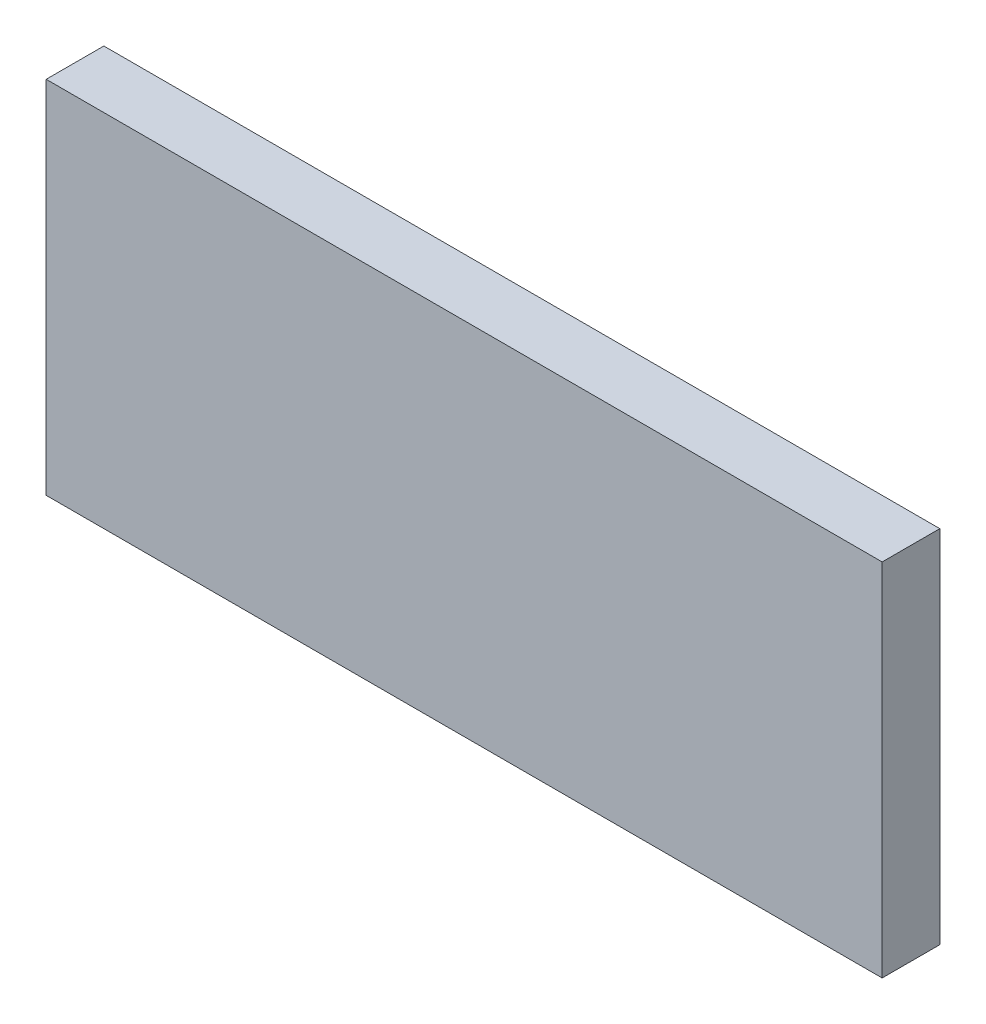
from build123d import *

# Parameters (mm, degrees)
SKETCH1_W           = 58
SKETCH1_H           = 25
BOSS_EXTRUDE1_DEPTH = 4


with BuildPart() as part:
    # Sketch1 → Boss-Extrude1 (new body)
    with BuildSketch(Plane.XY):
        Rectangle(SKETCH1_W, SKETCH1_H)
    extrude(amount=BOSS_EXTRUDE1_DEPTH)


solid = part.part
